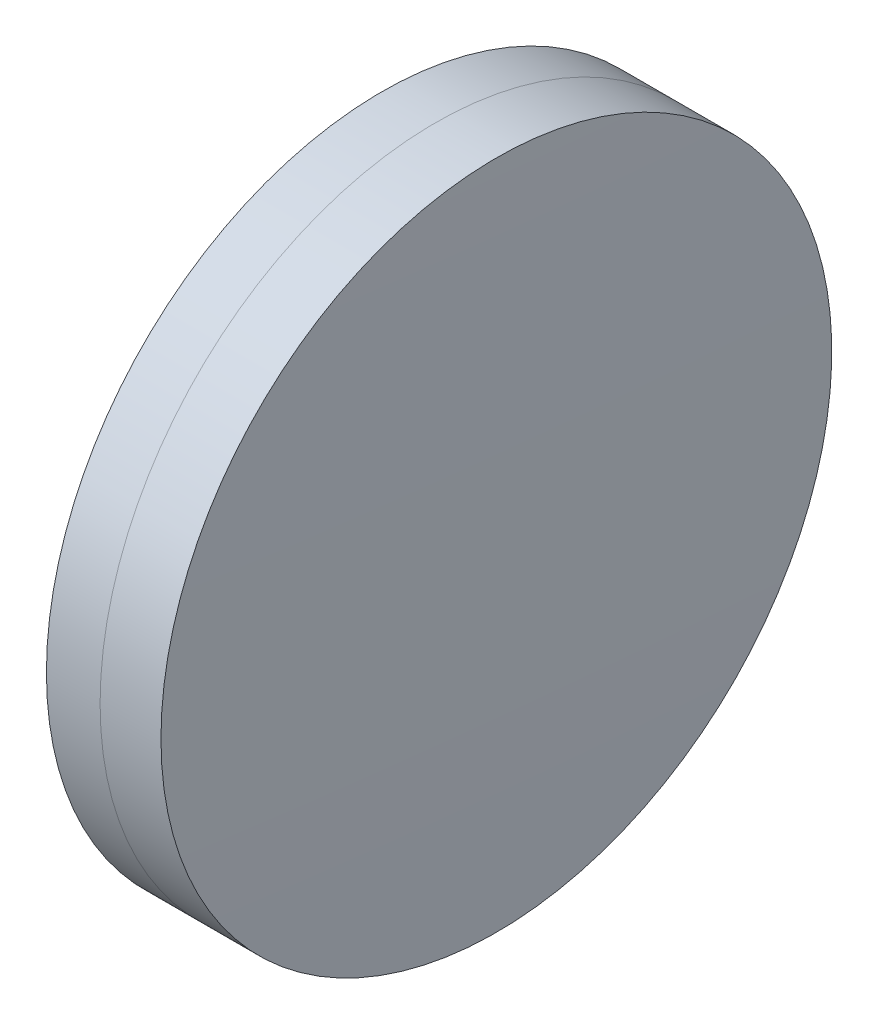
from build123d import *


with BuildPart() as part:
    # 草图1 one side → 旋转1 (revolve)
    with BuildSketch(Plane(origin=(0, 0, 0), x_dir=(1, 0, 0), z_dir=(0, 1, 0)), mode=Mode.PRIVATE) as revolve_1_sk:
        with BuildLine():
            ThreePointArc((215.49425336, 12.5), (215.303321669, 6.25129613), (215.239668974, 0))
            Line((215.239668974, 0), (217.879668974, 0))
            ThreePointArc((217.879668974, 0), (217.78334169, 6.252967149), (217.494451258, 12.5))
            Line((217.494451258, 12.5), (215.49425336, 12.5))
        make_face()
    revolve(revolve_1_sk.sketch.rotate(Axis((-9.702612178, 0, 0), (1, 0, 0)), 180), axis=Axis((-9.702612178, 0, 0), (1, 0, 0)))  # turned: the seam where the file's is


with BuildPart() as body_2:
    # 草图2 one side → 旋转3 (revolve)
    with BuildSketch(Plane(origin=(0, 0, 0), x_dir=(1, 0, 0), z_dir=(0, 1, 0)), mode=Mode.PRIVATE) as revolve_3_sk:
        with BuildLine():
            Line((219.763019521, 12.5), (217.494451258, 12.5))
            ThreePointArc((217.494451258, 12.5), (217.78334169, 6.252967149), (217.879668974, 0))
            Line((217.879668974, 0), (219.879668974, 0))
            ThreePointArc((219.879668974, 0), (219.850505975, 6.250272136), (219.763019521, 12.5))
        make_face()
    revolve(revolve_3_sk.sketch.rotate(Axis((-0.551919993, 0, 0), (1, 0, 0)), 180), axis=Axis((-0.551919993, 0, 0), (1, 0, 0)))  # turned: the seam where the file's is


solid = Compound([part.part, body_2.part])
